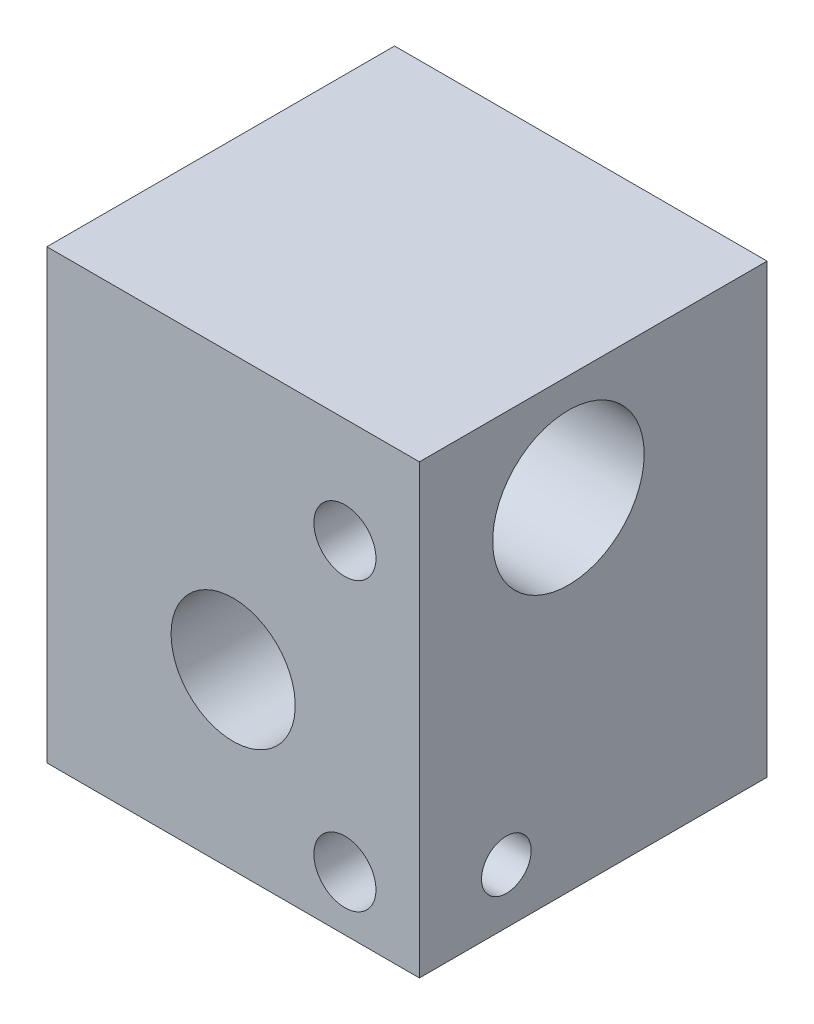
from build123d import *

# Parameters (mm, degrees)
SKETCH1_W                           = 15
SKETCH1_H                           = 18
BOSS_EXTRUDE1_DEPTH                 = 14
SKETCH2_R                           = 2.5
CUT_EXTRUDE1_DEPTH                  = 15
SKETCH3_R                           = 3.05
CUT_EXTRUDE2_DEPTH                  = 16
TALADRO_ROSCADO_M31_D               = 2.5
TALADRO_ROSCADO_M31_DEPTH           = 4
TALADRO_ROSCADO_M31_TIP             = 0.751075774
DI_METRO_DE_TALADRO_2_8_2_8_1_D     = 2
DI_METRO_DE_TALADRO_2_8_2_8_1_DEPTH = 12
DI_METRO_DE_TALADRO_2_8_2_8_1_TIP   = 0.600860619


with BuildPart() as part:
    # Sketch1 → Boss-Extrude1 (new body)
    with BuildSketch(Plane.XY):
        Rectangle(SKETCH1_W, SKETCH1_H)
    extrude(amount=BOSS_EXTRUDE1_DEPTH)

    # Sketch2 → Cut-Extrude1 (cut, through all)
    with BuildSketch(Plane(origin=(0, 0, 0), x_dir=(-1, 0, 0), z_dir=(0, 0, -1))):
        with Locations((0, -2)):
            Circle(SKETCH2_R)
    extrude(amount=-CUT_EXTRUDE1_DEPTH, mode=Mode.SUBTRACT)

    # Sketch3 → Cut-Extrude2 (cut, through all)
    with BuildSketch(Plane(origin=(7.5, 0, 0), x_dir=(0, 0, -1), z_dir=(1, 0, 0))):
        with Locations((-8, 4.75)):
            Circle(SKETCH3_R)
    extrude(amount=-CUT_EXTRUDE2_DEPTH, mode=Mode.SUBTRACT)

    # Taladro roscado M31
    with Locations(Plane(origin=(-2.648652683, -2.97524228, 14), x_dir=(1, 0, 0), z_dir=(0, 0, 1))):
        with Locations((7.148652683, 7.72524228), (7.148652683, -3.82475772)):
            Hole(TALADRO_ROSCADO_M31_D / 2, depth=TALADRO_ROSCADO_M31_DEPTH)
            with Locations((0, 0, -(TALADRO_ROSCADO_M31_DEPTH + TALADRO_ROSCADO_M31_TIP / 2))):  # 118° drill point
                Cone(0, TALADRO_ROSCADO_M31_D / 2, TALADRO_ROSCADO_M31_TIP, mode=Mode.SUBTRACT)

    # Diámetro de taladro Ø2.8 (2.8)1
    with Locations(Plane(origin=(7.5, -6.8, 10.5), x_dir=(0, 0, 1), z_dir=(1, 0, 0))):
        with Locations((0, 0)):
            Hole(DI_METRO_DE_TALADRO_2_8_2_8_1_D / 2, depth=DI_METRO_DE_TALADRO_2_8_2_8_1_DEPTH)
            with Locations((0, 0, -(DI_METRO_DE_TALADRO_2_8_2_8_1_DEPTH + DI_METRO_DE_TALADRO_2_8_2_8_1_TIP / 2))):  # 118° drill point
                Cone(0, DI_METRO_DE_TALADRO_2_8_2_8_1_D / 2, DI_METRO_DE_TALADRO_2_8_2_8_1_TIP, mode=Mode.SUBTRACT)


solid = part.part
